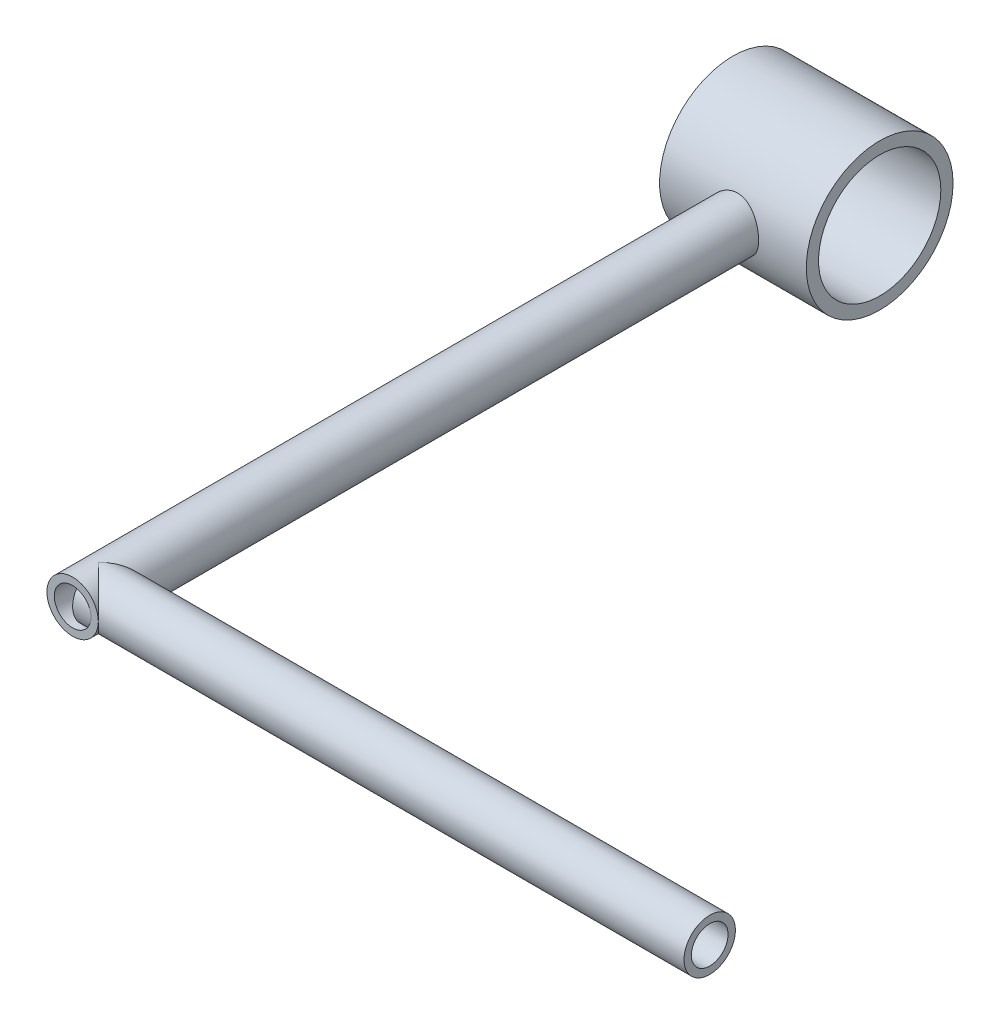
from build123d import *

# Parameters (mm, degrees)
SKETCH_1_R          = 10.5
EXTRUDE_1_DEPTH     = 300
SKETCH_2_R          = 7.5
CUT_EXTRUDE_1_DEPTH = 301
SKETCH_4_R          = 30
EXTRUDE_2_DEPTH     = 30
SKETCH_5_R          = 25
CUT_EXTRUDE_2_DEPTH = 61.0000001
SKETCH_7_R          = 10.5
SKETCH_7_R_2        = 7.5
EXTRUDE_4_DEPTH     = 250


with BuildPart() as part:
    # Эскиз1 → Бобышка-Вытянуть1 (new body)
    with BuildSketch(Plane.XY):
        Circle(SKETCH_1_R)
    extrude(amount=EXTRUDE_1_DEPTH)

    # Эскиз2 → Вырез-Вытянуть1 (cut, through all)
    with BuildSketch(Plane(origin=(0, 0, 0), x_dir=(-1, 0, 0), z_dir=(0, 0, -1))):
        Circle(SKETCH_2_R)
    extrude(amount=-CUT_EXTRUDE_1_DEPTH, mode=Mode.SUBTRACT)

    # Эскиз4 → Бобышка-Вытянуть2 (add, symmetric)
    with BuildSketch(Plane(origin=(0, 0, 0), x_dir=(0, 0, -1), z_dir=(1, 0, 0))):
        Circle(SKETCH_4_R)
    extrude(amount=EXTRUDE_2_DEPTH, both=True)

    # Эскиз5 → Вырез-Вытянуть2 (cut, through all)
    with BuildSketch(Plane(origin=(30, 0, 0), x_dir=(0, 0, -1), z_dir=(1, 0, 0))):
        Circle(SKETCH_5_R)
    extrude(amount=-CUT_EXTRUDE_2_DEPTH, mode=Mode.SUBTRACT)

    # Эскиз7 → Бобышка-Вытянуть4 (add)
    with BuildSketch(Plane(origin=(0, 0, 0), x_dir=(0, 0, -1), z_dir=(1, 0, 0))):
        with Locations((-289.5, 0)):
            Circle(SKETCH_7_R)
        with Locations((-289.5, 0)):
            Circle(SKETCH_7_R_2, mode=Mode.SUBTRACT)
    extrude(amount=EXTRUDE_4_DEPTH)


solid = part.part
